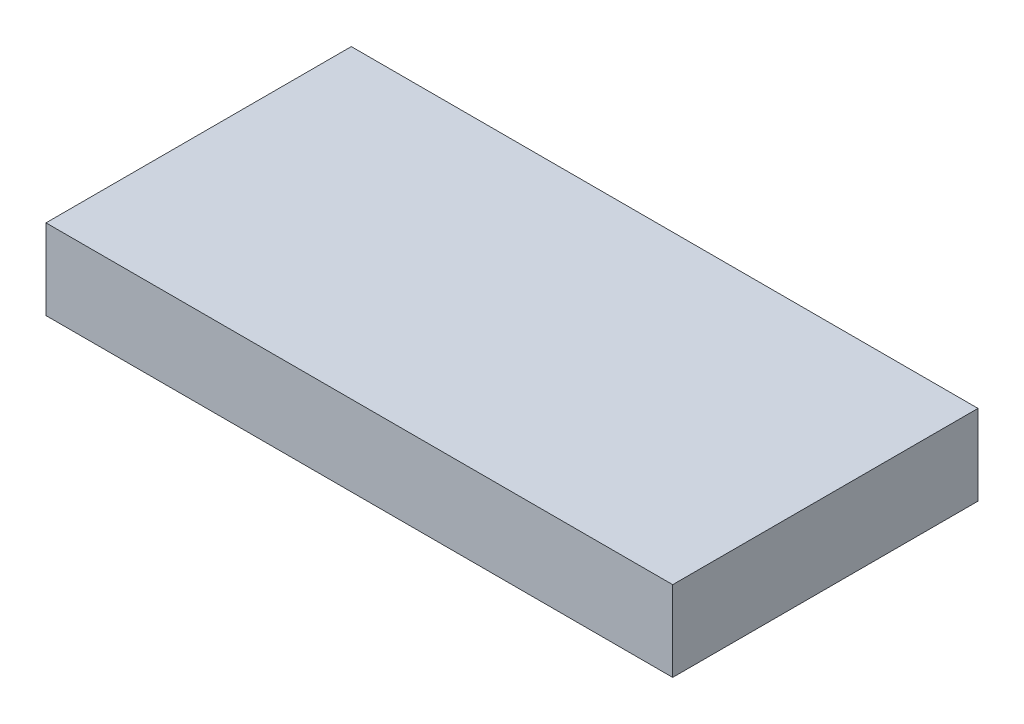
from build123d import *

# Parameters (mm, degrees)
SKETCH1_W           = 39
SKETCH1_H           = 19
BOSS_EXTRUDE1_DEPTH = 5


with BuildPart() as part:
    # Sketch1 → Boss-Extrude1 (new body)
    with BuildSketch(Plane(origin=(0, 0, 0), x_dir=(1, 0, 0), z_dir=(0, 1, 0))):
        Rectangle(SKETCH1_W, SKETCH1_H)
    extrude(amount=BOSS_EXTRUDE1_DEPTH)


solid = part.part
